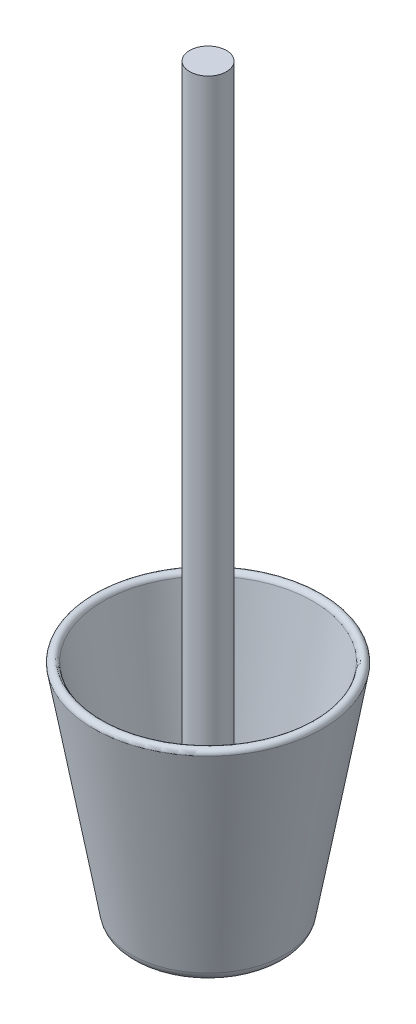
from build123d import *

# Parameters (mm, degrees)
ESQUISSE1_R        = 12.5
BOSS_EXTRU_2_DEPTH = 500


with BuildPart() as part:
    # Sketch1 → Revolve1 (revolve)
    with BuildSketch(Plane.XY):
        with BuildLine():
            Line((0, 0), (44.139646678, 0))
            ThreePointArc((44.139646678, 0), (49.241773329, 1.857022233), (51.956558217, 6.55916759))
            Line((51.956558217, 6.55916759), (77.67223186, 152.4))
            ThreePointArc((77.67223186, 152.4), (74.751767132, 155.587127984), (71.32223186, 152.955553013))
            Line((71.32223186, 152.955553013), (45.703028985, 7.661833518))
            ThreePointArc((45.703028985, 7.661833518), (45.160072008, 6.721404447), (44.139646678, 6.35))
            Line((44.139646678, 6.35), (0, 6.35))
            Line((0, 6.35), (0, 0))
        make_face()
    revolve(axis=Axis((0, 0, 0), (0, 1, 0)))

    # Esquisse1 → Boss.-Extru.2 (add)
    with BuildSketch(Plane(origin=(0, 6.35, 0), x_dir=(1, 0, 0), z_dir=(0, 1, 0))):
        Circle(ESQUISSE1_R)
    extrude(amount=BOSS_EXTRU_2_DEPTH)


solid = part.part
